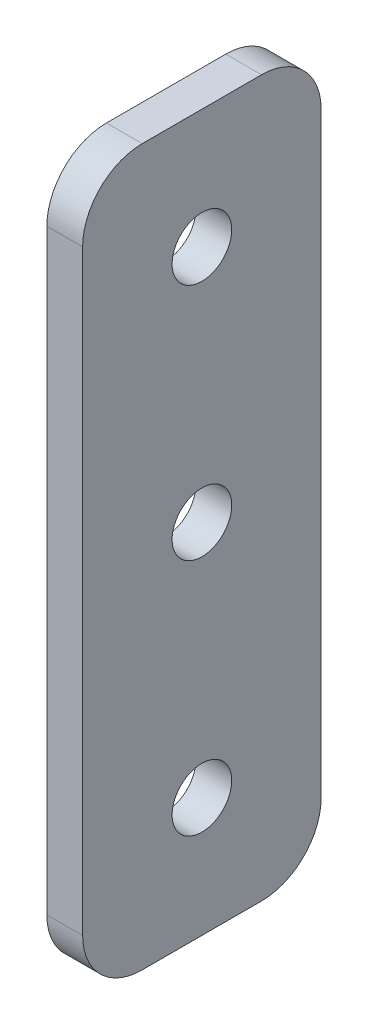
from build123d import *

# Parameters (mm, degrees)
SKETCH1_W           = 20
SKETCH1_H           = 60
SKETCH1_R           = 2.5
BOSS_EXTRUDE1_DEPTH = 3
FILLET1_R           = 5


with BuildPart() as part:
    # Sketch1 → Boss-Extrude1 (new body)
    with BuildSketch(Plane(origin=(0, 0, 0), x_dir=(0, 0, -1), z_dir=(1, 0, 0))):
        with Locations((0, 30)):
            Rectangle(SKETCH1_W, SKETCH1_H)
        with Locations((0, 10)):
            Circle(SKETCH1_R, mode=Mode.SUBTRACT)
        with Locations((0, 30)):
            Circle(SKETCH1_R, mode=Mode.SUBTRACT)
        with Locations((0, 50)):
            Circle(SKETCH1_R, mode=Mode.SUBTRACT)
    extrude(amount=BOSS_EXTRUDE1_DEPTH)

    # Fillet1
    fillet1_edges = [part.edges().sort_by_distance(p)[0] for p in [
        (1.5, 60, 10),
        (1.5, 60, -10),
        (1.5, 0, -10),
        (1.5, 0, 10),
    ]]
    fillet(fillet1_edges, radius=FILLET1_R)


solid = part.part
